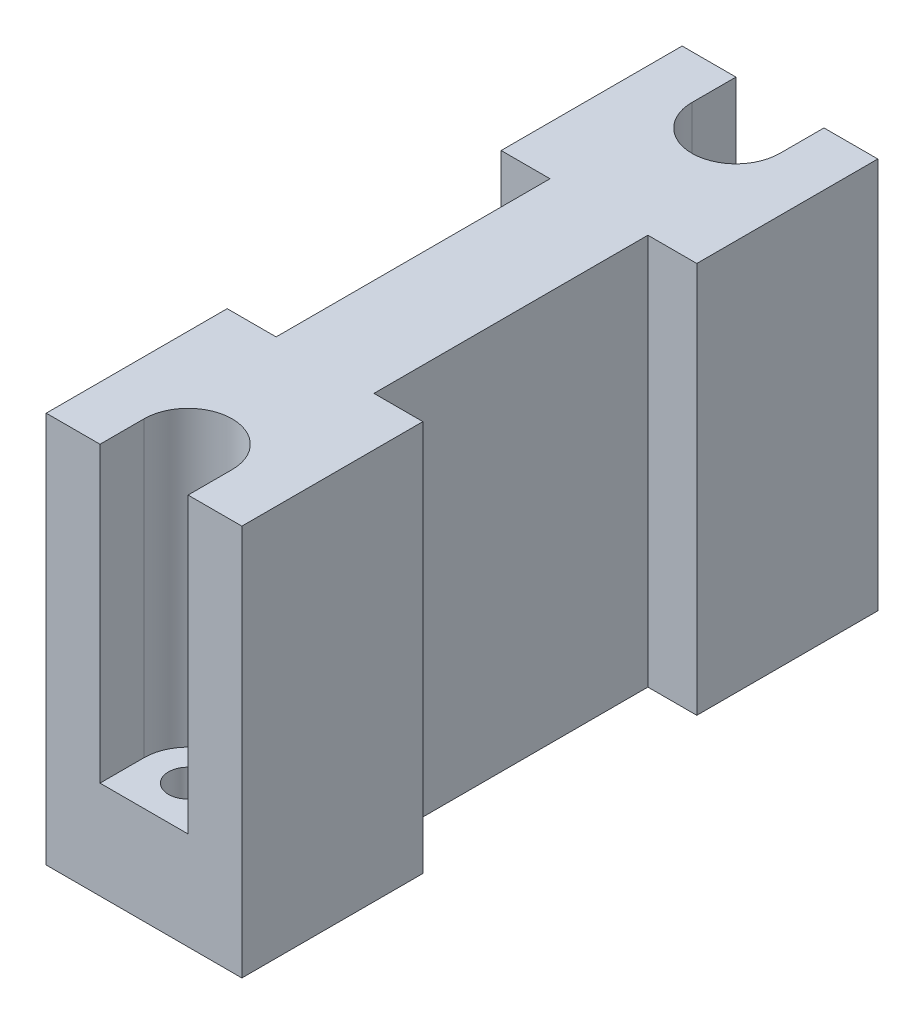
from build123d import *

# Parameters (mm, degrees)
SKETCH1_W           = 20
SKETCH1_H           = 65
BOSS_EXTRUDE1_DEPTH = 40
SKETCH2_R           = 2
SKETCH2_W           = 5
SKETCH2_H           = 28
CUT_EXTRUDE1_DEPTH  = 40
SKETCH4_R           = 4.5
SKETCH4_W           = 9
SKETCH4_H           = 4.5
CUT_EXTRUDE4_DEPTH  = 30


with BuildPart() as part:
    # Sketch1 → Boss-Extrude1 (new body)
    with BuildSketch(Plane(origin=(0, 0, 0), x_dir=(1, 0, 0), z_dir=(0, 1, 0))):
        with Locations((10, 32.5)):
            Rectangle(SKETCH1_W, SKETCH1_H)
    extrude(amount=BOSS_EXTRUDE1_DEPTH)

    # Sketch2 → Cut-Extrude1 (cut)
    with BuildSketch(Plane(origin=(0, 40, 0), x_dir=(1, 0, 0), z_dir=(0, 1, 0))):
        with Locations((10, 60.5)):
            Circle(SKETCH2_R)
        with Locations((10, 4.5)):
            Circle(SKETCH2_R)
        with Locations((17.5, 32.5)):
            Rectangle(SKETCH2_W, SKETCH2_H)
        with Locations((2.5, 32.5)):
            Rectangle(SKETCH2_W, SKETCH2_H)
    extrude(amount=-CUT_EXTRUDE1_DEPTH, mode=Mode.SUBTRACT)

    # Sketch4 → Cut-Extrude4 (cut)
    with BuildSketch(Plane(origin=(0, 40, 0), x_dir=(1, 0, 0), z_dir=(0, 1, 0))):
        with Locations((10, 4.5)):
            Circle(SKETCH4_R)
        with Locations((10, 60.5)):
            Circle(SKETCH4_R)
        with Locations((10, 2.25)):
            Rectangle(SKETCH4_W, SKETCH4_H)
        with Locations((10, 62.75)):
            Rectangle(SKETCH4_W, SKETCH4_H)
    extrude(amount=-CUT_EXTRUDE4_DEPTH, mode=Mode.SUBTRACT)


solid = part.part
